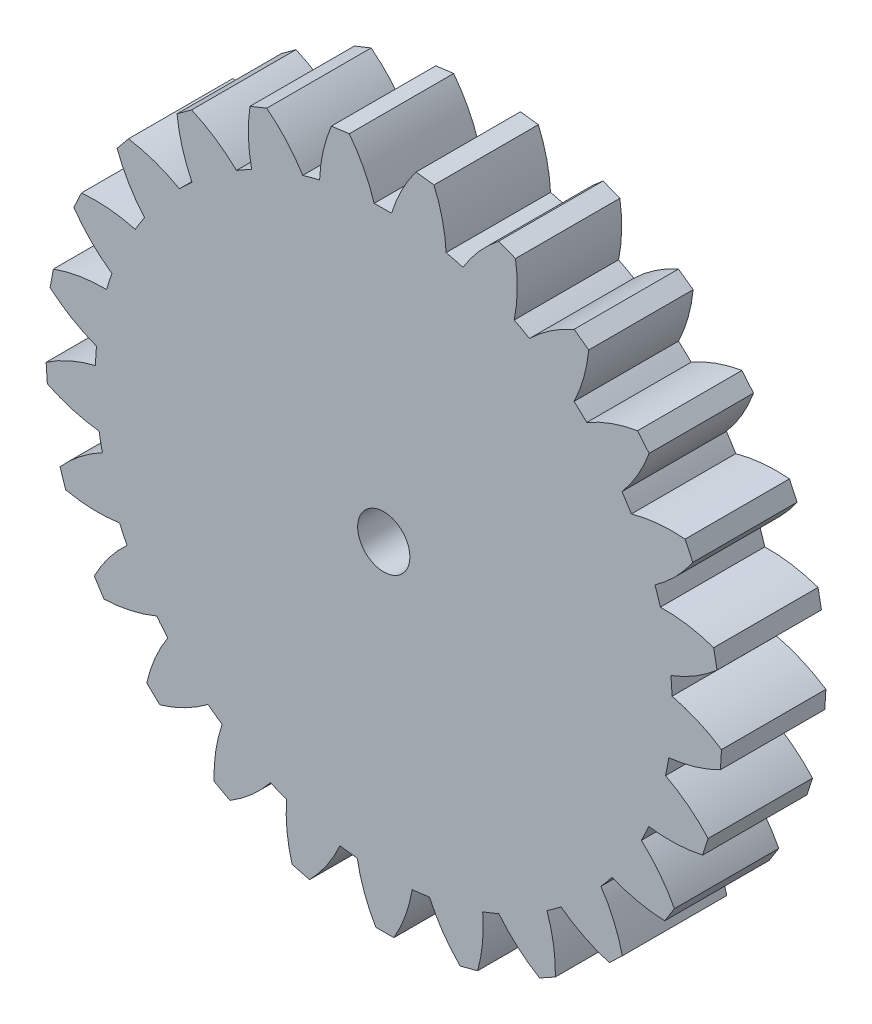
from build123d import *

# Parameters (mm, degrees)
SKETCH1_R        = 3.175
EXTRUSION2_DEPTH = 12.7


with BuildPart() as part:
    # Sketch1 → Extrusion2 (new body)
    with BuildSketch(Plane.XY):
        with BuildLine():
            Line((-14.233622753, 38.567186329), (-16.273931786, 37.751596287))
            ThreePointArc((-16.273931786, 37.751596287), (-16.466248372, 34.463305312), (-16.071921005, 31.19308374))
            ThreePointArc((-16.071921005, 31.19308374), (-17.005853093, 30.69390947), (-17.924297324, 30.166781125))
            ThreePointArc((-17.924297324, 30.166781125), (-20.487810109, 32.23517311), (-23.377716537, 33.815769214))
            Line((-23.377716537, 33.815769214), (-25.151096514, 32.51839821))
            ThreePointArc((-25.151096514, 32.51839821), (-24.51960641, 29.285587753), (-23.324396528, 26.216171433))
            ThreePointArc((-23.324396528, 26.216171433), (-24.10484783, 25.500420175), (-24.863345957, 24.761444744))
            ThreePointArc((-24.863345957, 24.761444744), (-27.860709444, 26.127334686), (-31.052902414, 26.939582953))
            Line((-31.052902414, 26.939582953), (-32.447925349, 25.241949579))
            ThreePointArc((-32.447925349, 25.241949579), (-31.0323074, 22.26774901), (-29.111314436, 19.592000659))
            ThreePointArc((-29.111314436, 19.592000659), (-29.689246325, 18.704645697), (-30.240139123, 17.800255724))
            ThreePointArc((-30.240139123, 17.800255724), (-33.483017939, 18.377819734), (-36.776920227, 18.370683619))
            Line((-36.776920227, 18.370683619), (-37.7059317, 16.379456422))
            ThreePointArc((-37.7059317, 16.379456422), (-35.595134387, 13.850745701), (-33.069061394, 11.736792429))
            ThreePointArc((-33.069061394, 11.736792429), (-33.408160285, 10.733589538), (-33.716833132, 9.720611171))
            ThreePointArc((-33.716833132, 9.720611171), (-37.001465276, 9.47355878), (-40.190108886, 8.64748667))
            Line((-40.190108886, 8.64748667), (-40.594735688, 6.487781779))
            ThreePointArc((-40.594735688, 6.487781779), (-37.921388171, 4.563449101), (-34.948957606, 3.144118365))
            ThreePointArc((-34.948957606, 3.144118365), (-35.027916668, 2.088102473), (-35.074974514, 1.030184869))
            ThreePointArc((-35.074974514, 1.030184869), (-38.194974467, -0.025960715), (-41.078005196, -1.619063669))
            Line((-41.078005196, -1.619063669), (-40.932823137, -3.811544054))
            ThreePointArc((-40.932823137, -3.811544054), (-37.864901671, -5.01058579), (-34.632882277, -5.646112218))
            ThreePointArc((-34.632882277, -5.646112218), (-34.446740222, -6.688587749), (-34.22922625, -7.724971737))
            ThreePointArc((-34.22922625, -7.724971737), (-36.988552942, -9.523849001), (-39.384819364, -11.783882284))
            Line((-39.384819364, -11.783882284), (-38.698950767, -13.871376555))
            ThreePointArc((-38.698950767, -13.871376555), (-35.429224142, -14.269787147), (-32.140695585, -14.081576806))
            ThreePointArc((-32.140695585, -14.081576806), (-31.701148402, -15.045009405), (-31.232729815, -15.994739958))
            ThreePointArc((-31.232729815, -15.994739958), (-33.4580046, -18.423318829), (-35.216940485, -21.208276236))
            Line((-35.216940485, -21.208276236), (-34.033480996, -23.059619453))
            ThreePointArc((-34.033480996, -23.059619453), (-30.76739816, -22.632365298), (-27.628990783, -21.632244135))
            ThreePointArc((-27.628990783, -21.632244135), (-26.96365684, -22.456097788), (-26.273766099, -23.259499844))
            ThreePointArc((-26.273766099, -23.259499844), (-27.82516678, -26.165183779), (-28.836251716, -29.300076195))
            Line((-28.836251716, -29.300076195), (-27.229562447, -30.798941653))
            ThreePointArc((-27.229562447, -30.798941653), (-24.172343397, -29.572868701), (-21.381254878, -27.823678007))
            ThreePointArc((-21.381254878, -27.823678007), (-20.531939552, -28.456186959), (-19.663925031, -29.062779812))
            ThreePointArc((-19.663925031, -29.062779812), (-20.443971397, -32.262994003), (-20.643675199, -35.550844607))
            Line((-20.643675199, -35.550844607), (-18.714710347, -36.603053078))
            ThreePointArc((-18.714710347, -36.603053078), (-16.058451399, -34.655200002), (-13.790056095, -32.266847861))
            ThreePointArc((-13.790056095, -32.266847861), (-12.810124992, -32.668269249), (-11.818527235, -33.039938438))
            ThreePointArc((-11.818527235, -33.039938438), (-11.778206103, -36.333601659), (-11.153980648, -39.567822706))
            Line((-11.153980648, -39.567822706), (-9.023944168, -40.107260062))
            ThreePointArc((-9.023944168, -40.107260062), (-6.935547841, -37.560017634), (-5.332377371, -34.682572995))
            ThreePointArc((-5.332377371, -34.682572995), (-4.283403166, -34.827684036), (-3.230527907, -34.941076221))
            ThreePointArc((-3.230527907, -34.941076221), (-2.372372803, -38.121235497), (-0.963440471, -41.098608985))
            Line((-0.963440471, -41.098608985), (1.233829612, -41.091380392))
            ThreePointArc((1.233829612, -41.091380392), (2.623141695, -38.104801222), (3.460354235, -34.919064515))
            ThreePointArc((3.460354235, -34.919064515), (4.512460635, -34.798747349), (5.560457371, -34.64673768))
            ThreePointArc((5.560457371, -34.64673768), (7.182525405, -37.513571908), (9.287636214, -40.04701851))
            Line((9.287636214, -40.04701851), (11.414077338, -39.493578168))
            ThreePointArc((11.414077338, -39.493578168), (12.017009592, -36.255320009), (12.035659057, -32.961462787))
            ThreePointArc((12.035659057, -32.961462787), (13.024789938, -32.583277384), (14.002058661, -32.175417188))
            ThreePointArc((14.002058661, -32.175417188), (16.286119127, -34.548792632), (18.955136559, -36.47912658))
            Line((18.955136559, -36.47912658), (20.877136608, -35.414249181))
            ThreePointArc((20.877136608, -35.414249181), (20.65580458, -32.127783703), (19.854719157, -28.932771129))
            ThreePointArc((19.854719157, -28.932771129), (20.718723787, -28.320480269), (21.563859111, -27.682396902))
            ThreePointArc((21.563859111, -27.682396902), (24.366396088, -29.413185652), (27.431615961, -30.619116966))
            Line((27.431615961, -30.619116966), (29.028408604, -29.109712673))
            ThreePointArc((29.028408604, -29.109712673), (27.9967194, -25.981540589), (26.426234232, -23.086127053))
            ThreePointArc((26.426234232, -23.086127053), (27.110824023, -22.278203223), (27.770722986, -21.44998981))
            ThreePointArc((27.770722986, -21.44998981), (30.915642769, -22.429440044), (34.184466045, -22.835195624))
            Line((34.184466045, -22.835195624), (35.355718928, -20.97610586))
            ThreePointArc((35.355718928, -20.97610586), (33.578497375, -18.202781726), (31.337291821, -15.78889671))
            ThreePointArc((31.337291821, -15.78889671), (31.799451478, -14.836104734), (32.232650202, -13.869800971))
            ThreePointArc((32.232650202, -13.869800971), (35.522345915, -14.036370229), (38.789380407, -13.616454959))
            Line((38.789380407, -13.616454959), (39.461499403, -11.524493171))
            ThreePointArc((39.461499403, -11.524493171), (37.050414867, -9.280275142), (34.279312115, -7.499591919))
            ThreePointArc((34.279312115, -7.499591919), (34.490002447, -6.461799222), (34.669281463, -5.418121527))
            ThreePointArc((34.669281463, -5.418121527), (37.897049426, -4.761343649), (40.95701534, -3.542142351))
            Line((40.95701534, -3.542142351), (41.087768741, -1.348754192))
            ThreePointArc((41.087768741, -1.348754192), (38.194318531, 0.225345259), (35.067437158, 1.260939814))
            ThreePointArc((35.067437158, 1.260939814), (35.013419717, 2.318524899), (34.927514264, 3.373998419))
            ThreePointArc((34.927514264, 3.373998419), (37.890541945, 4.812855662), (40.55117037, 6.754736088))
            Line((40.55117037, 6.754736088), (40.132342459, 8.911731973))
            ThreePointArc((40.132342459, 8.911731973), (36.938332693, 9.716806389), (33.652146155, 9.942242061))
            ThreePointArc((33.652146155, 9.942242061), (33.336815056, 10.953167575), (32.99112289, 11.954117636))
            ThreePointArc((32.99112289, 11.954117636), (35.503232362, 14.084645553), (37.597346229, 16.627189616))
            Line((37.597346229, 16.627189616), (36.655253504, 18.612261243))
            ThreePointArc((36.655253504, 18.612261243), (33.361375562, 18.597724838), (30.122367045, 17.998836674))
            ThreePointArc((30.122367045, 17.998836674), (29.565535701, 18.899582449), (28.981777932, 19.783115677))
            ThreePointArc((28.981777932, 19.783115677), (30.885124119, 22.471445363), (32.281142551, 25.454895671))
            Line((32.281142551, 25.454895671), (30.874980162, 27.143313689))
            ThreePointArc((30.874980162, 27.143313689), (27.68820051, 26.310079837), (24.699888832, 24.924498184))
            ThreePointArc((24.699888832, 24.924498184), (23.936545003, 25.65846705), (23.151401279, 26.369067803))
            ThreePointArc((23.151401279, 26.369067803), (24.326389939, 29.446281617), (24.936595965, 32.683177014))
            Line((24.936595965, 32.683177014), (23.154718267, 33.968851909))
            ThreePointArc((23.154718267, 33.968851909), (20.27527399, 32.369275759), (17.725425763, 30.284061807))
            ThreePointArc((17.725425763, 30.284061807), (16.80353315, 30.805135801), (15.866336939, 31.298154421))
            ThreePointArc((15.866336939, 31.298154421), (16.239139213, 34.570899701), (16.025191344, 37.857854144))
            Line((16.025191344, 37.857854144), (13.979560266, 38.660002235))
            ThreePointArc((13.979560266, 38.660002235), (11.588377438, 36.394591039), (9.637209004, 33.74076645))
            ThreePointArc((9.637209004, 33.74076645), (8.61469351, 34.016204576), (7.584332296, 34.26066289))
            ThreePointArc((7.584332296, 34.26066289), (7.131523647, 37.523301014), (6.106865014, 40.653783068))
            Line((6.106865014, 40.653783068), (3.92601508, 40.922002439))
            ThreePointArc((3.92601508, 40.922002439), (2.173340512, 38.133100314), (0.943450961, 35.077414647))
            ThreePointArc((0.943450961, 35.077414647), (-0.115439006, 35.089910115), (-1.174223838, 35.070447907))
            ThreePointArc((-1.174223838, 35.070447907), (-2.424191777, 38.117975323), (-4.195178104, 40.895285287))
            Line((-4.195178104, 40.895285287), (-6.374216073, 40.612722729))
            ThreePointArc((-6.374216073, 40.612722729), (-7.378255391, 37.475566652), (-7.809587577, 34.210019876))
            ThreePointArc((-7.809587577, 34.210019876), (-8.838318064, 33.958787549), (-9.858999169, 33.676627702))
            ThreePointArc((-9.858999169, 33.676627702), (-11.827586317, 36.317557055), (-14.233622753, 38.567186329))
        make_face()
        Circle(SKETCH1_R, mode=Mode.SUBTRACT)
    extrude(amount=EXTRUSION2_DEPTH)


solid = part.part
